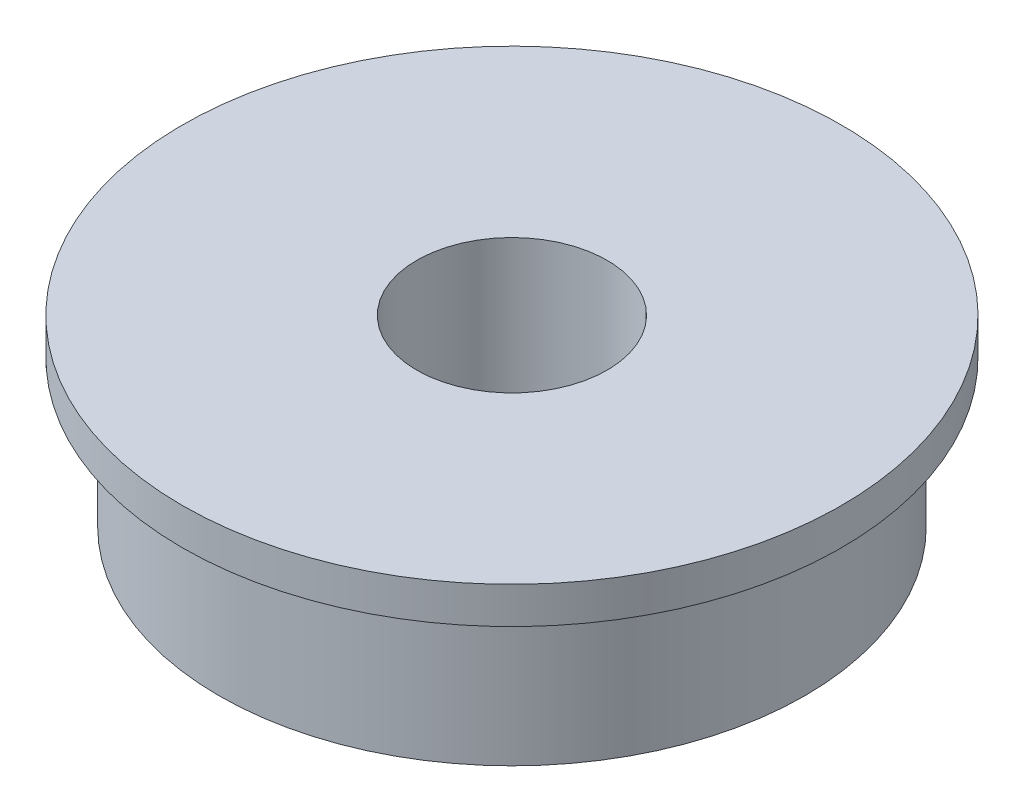
from build123d import *

# Parameters (mm, degrees)
SKETCH_1_R      = 8
SKETCH_1_R_2    = 2.6
EXTRUDE_1_DEPTH = 5
SKETCH_2_R      = 9
SKETCH_2_R_2    = 2.6
EXTRUDE_2_DEPTH = 1


with BuildPart() as part:
    # 草图1 → 凸台-拉伸1 (new body)
    with BuildSketch(Plane(origin=(0, 0, 0), x_dir=(1, 0, 0), z_dir=(0, 1, 0))):
        Circle(SKETCH_1_R)
        Circle(SKETCH_1_R_2, mode=Mode.SUBTRACT)
    extrude(amount=EXTRUDE_1_DEPTH)

    # 草图2 → 凸台-拉伸2 (add)
    with BuildSketch(Plane(origin=(0, 5, 0), x_dir=(1, 0, 0), z_dir=(0, 1, 0))):
        Circle(SKETCH_2_R)
        Circle(SKETCH_2_R_2, mode=Mode.SUBTRACT)
    extrude(amount=-EXTRUDE_2_DEPTH)


solid = part.part
